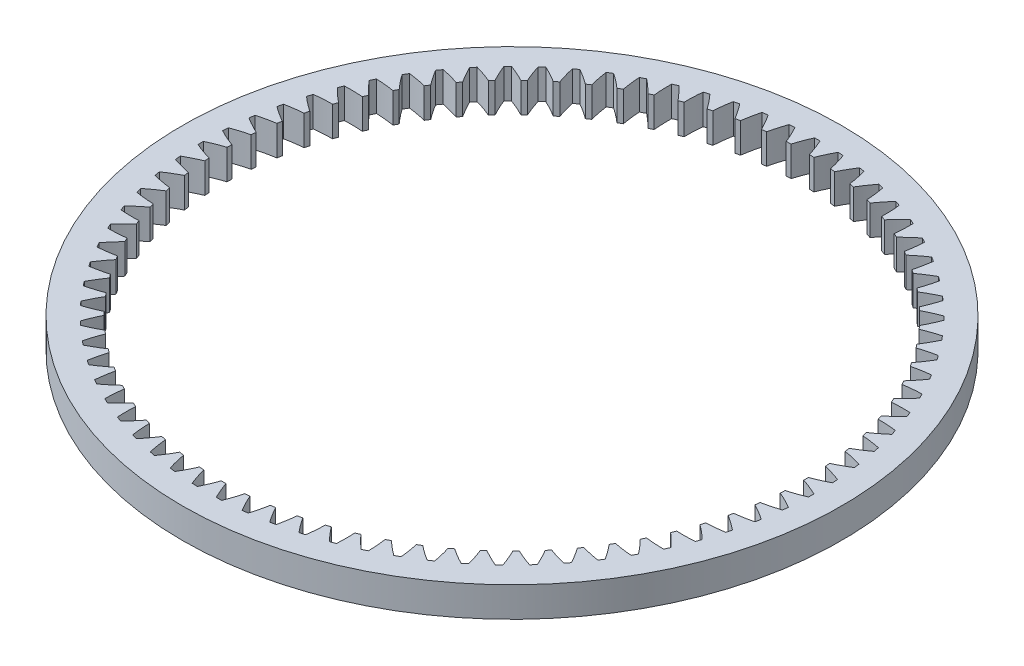
from build123d import *

# Parameters (mm, degrees)
SKETCH1_R           = 34.925
BOSS_EXTRUDE1_DEPTH = 3.175


with BuildPart() as part:
    # Sketch1 → Boss-Extrude1 (new body)
    with BuildSketch(Plane(origin=(0, 0, 0), x_dir=(1, 0, 0), z_dir=(0, 1, 0))):
        Circle(SKETCH1_R)
        with BuildLine():
            ThreePointArc((-21.018450197, 24.604762777), (-21.235465246, 24.417711108), (-21.450815724, 24.228745423))
            ThreePointArc((-21.450815724, 24.228745423), (-21.140636423, 23.310386195), (-20.774375306, 22.412918834))
            ThreePointArc((-20.774375306, 22.412918834), (-20.955169098, 22.243976445), (-21.134589057, 22.073575728))
            ThreePointArc((-21.134589057, 22.073575728), (-22.008625513, 22.492688056), (-22.906860003, 22.857063783))
            ThreePointArc((-22.906860003, 22.857063783), (-23.108327747, 22.653361533), (-23.307984112, 22.447883567))
            ThreePointArc((-23.307984112, 22.447883567), (-22.925821544, 21.557071218), (-22.489414305, 20.691540403))
            ThreePointArc((-22.489414305, 20.691540403), (-22.656214078, 20.508767971), (-22.821528496, 20.324650972))
            ThreePointArc((-22.821528496, 20.324650972), (-23.726100526, 20.672996076), (-24.650445265, 20.964855073))
            ThreePointArc((-24.650445265, 20.964855073), (-24.835091959, 20.745790112), (-25.017791919, 20.525098964))
            ThreePointArc((-25.017791919, 20.525098964), (-24.566062239, 19.667465496), (-24.062267985, 18.839343391))
            ThreePointArc((-24.062267985, 18.839343391), (-24.214019177, 18.643896462), (-24.364182883, 18.447227229))
            ThreePointArc((-24.364182883, 18.447227229), (-25.293571493, 18.722602759), (-26.238182475, 18.940099799))
            ThreePointArc((-26.238182475, 18.940099799), (-26.404840724, 18.707057127), (-26.569429191, 18.472548077))
            ThreePointArc((-26.569429191, 18.472548077), (-26.050988379, 17.653515724), (-25.482992261, 16.868037984))
            ThreePointArc((-25.482992261, 16.868037984), (-25.618735451, 16.661152237), (-25.752799063, 16.453174175))
            ThreePointArc((-25.752799063, 16.453174175), (-26.701128357, 16.653839119), (-27.660033448, 16.795599116))
            ThreePointArc((-27.660033448, 16.795599116), (-27.807649584, 16.550052104), (-27.953085978, 16.303207793))
            ThreePointArc((-27.953085978, 16.303207793), (-27.371211783, 15.527954743), (-26.742604854, 14.790087411))
            ThreePointArc((-26.742604854, 14.790087411), (-26.861481832, 14.573070844), (-26.978597754, 14.355098857))
            ThreePointArc((-26.978597754, 14.355098857), (-27.93987209, 14.479784546), (-28.907008784, 14.544911247))
            ThreePointArc((-28.907008784, 14.544911247), (-29.03464953, 14.288412322), (-29.160014354, 14.03079338))
            ThreePointArc((-29.160014354, 14.03079338), (-28.518385573, 13.304221032), (-27.833142089, 12.618629143))
            ThreePointArc((-27.833142089, 12.618629143), (-27.934401275, 12.392853804), (-28.033829065, 12.166265983))
            ThreePointArc((-28.033829065, 12.166265983), (-29.001970957, 12.214184114), (-29.971224702, 12.202265767))
            ThreePointArc((-29.971224702, 12.202265767), (-30.078083073, 11.936436598), (-30.182583731, 11.669671774))
            ThreePointArc((-30.182583731, 11.669671774), (-29.485256947, 10.996373752), (-28.747709239, 10.367391838))
            ThreePointArc((-28.747709239, 10.367391838), (-28.83071044, 10.134285153), (-28.911821482, 9.900514057))
            ThreePointArc((-28.911821482, 9.900514057), (-29.880710025, 9.871361676), (-30.845952889, 9.782473633))
            ThreePointArc((-30.845952889, 9.782473633), (-30.931353291, 9.508994878), (-31.014329096, 9.234770746))
            ThreePointArc((-31.014329096, 9.234770746), (-30.265713034, 8.619003856), (-29.480524114, 8.050608544))
            ThreePointArc((-29.480524114, 8.050608544), (-29.54474257, 7.811644287), (-29.607024055, 7.572167894))
            ThreePointArc((-29.607024055, 7.572167894), (-30.570533624, 7.466129312), (-31.525663029, 7.300833552))
            ThreePointArc((-31.525663029, 7.300833552), (-31.589065535, 7.02143423), (-31.649991887, 6.741484524))
            ThreePointArc((-31.649991887, 6.741484524), (-30.854819538, 6.187141843), (-30.026953625, 5.682926711))
            ThreePointArc((-30.026953625, 5.682926711), (-30.071983325, 5.439615692), (-30.115041489, 5.195948048))
            ThreePointArc((-30.115041489, 5.195948048), (-31.067080466, 5.013693675), (-32.006057778, 4.77303525))
            ThreePointArc((-32.006057778, 4.77303525), (-32.047061535, 4.489481815), (-32.085553238, 4.205576466))
            ThreePointArc((-32.085553238, 4.205576466), (-31.248851939, 3.716162728), (-30.383543067, 3.279315586))
            ThreePointArc((-30.383543067, 3.279315586), (-30.40909932, 3.033196095), (-30.432661935, 2.786877745))
            ThreePointArc((-30.432661935, 2.786877745), (-31.367211223, 2.529559852), (-32.284099925, 2.215060283))
            ThreePointArc((-32.284099925, 2.215060283), (-32.302445694, 1.92914545), (-32.318259391, 1.643079399))
            ThreePointArc((-32.318259391, 1.643079399), (-31.445319037, 1.221688835), (-30.548037967, 0.854971572))
            ThreePointArc((-30.548037967, 0.854971572), (-30.553959198, 0.607599655), (-30.557877293, 0.360187904))
            ThreePointArc((-30.557877293, 0.360187904), (-31.469028371, 0.029433337), (-32.358031597, -0.356919009))
            ThreePointArc((-32.358031597, -0.356919009), (-32.353603391, -0.643387593), (-32.346639103, -0.929805744))
            ThreePointArc((-32.346639103, -0.929805744), (-31.442978703, -1.280508968), (-30.519398335, -1.574777848))
            ThreePointArc((-30.519398335, -1.574777848), (-30.505647108, -1.821838225), (-30.489895913, -2.068779161))
            ThreePointArc((-30.489895913, -2.068779161), (-31.37188819, -2.470879265), (-32.227385375, -2.926641744))
            ThreePointArc((-32.227385375, -2.926641744), (-32.200211191, -3.211852933), (-32.170512948, -3.496812356))
            ThreePointArc((-32.170512948, -3.496812356), (-31.241845734, -3.774610981), (-30.297805241, -3.994571015))
            ThreePointArc((-30.297805241, -3.994571015), (-30.264468495, -4.239757858), (-30.229147594, -4.484666739))
            ThreePointArc((-30.229147594, -4.484666739), (-31.076404831, -4.955570173), (-31.892987246, -5.477861307))
            ThreePointArc((-31.892987246, -5.477861307), (-31.843238888, -5.760011904), (-31.790994452, -6.041710994))
            ThreePointArc((-31.790994452, -6.041710994), (-30.843191758, -6.244848688), (-29.884659667, -6.389109219))
            ThreePointArc((-29.884659667, -6.389109219), (-29.831948169, -6.630872376), (-29.777280871, -6.872200809))
            ThreePointArc((-29.777280871, -6.872200809), (-30.584446434, -7.408930371), (-31.356951384, -7.994448068))
            ThreePointArc((-31.356951384, -7.994448068), (-31.284943376, -8.271754226), (-31.210483054, -8.548411991))
            ThreePointArc((-31.210483054, -8.548411991), (-30.249537192, -8.675604451), (-29.282573652, -8.743253416))
            ThreePointArc((-29.282573652, -8.743253416), (-29.210820661, -8.980064384), (-29.13715259, -9.216286613))
            ThreePointArc((-29.13715259, -9.216286613), (-29.899123321, -9.815448925), (-30.622666779, -10.460491353))
            ThreePointArc((-30.622666779, -10.460491353), (-30.528854379, -10.731199854), (-30.432648932, -11.001067174))
            ThreePointArc((-30.432648932, -11.001067174), (-29.464635313, -11.05151025), (-28.495353779, -11.042119951))
            ThreePointArc((-28.495353779, -11.042119951), (-28.405012939, -11.272481533), (-28.31280985, -11.502104086))
            ThreePointArc((-28.31280985, -11.502104086), (-29.024768322, -12.159911051), (-29.694775815, -12.860400045))
            ThreePointArc((-29.694775815, -12.860400045), (-29.579752135, -13.122799382), (-29.462409806, -13.384170069))
            ThreePointArc((-29.462409806, -13.384170069), (-28.493448523, -13.357544842), (-27.527977105, -13.271174648))
            ThreePointArc((-27.527977105, -13.271174648), (-27.419619581, -13.493630425), (-27.30946441, -13.715201553))
            ThreePointArc((-27.30946441, -13.715201553), (-27.966909394, -14.427494304), (-28.579144917, -15.179001147))
            ThreePointArc((-28.579144917, -15.179001147), (-28.443637175, -15.431432346), (-28.305899839, -15.682653931))
            ThreePointArc((-28.305899839, -15.682653931), (-27.342116977, -15.579128735), (-26.386559696, -15.416324705))
            ThreePointArc((-26.386559696, -15.416324705), (-26.260870559, -15.629468241), (-26.133459743, -15.8415871))
            ThreePointArc((-26.133459743, -15.8415871), (-26.73223466, -16.603862293), (-27.282827463, -17.401635716))
            ThreePointArc((-27.282827463, -17.401635716), (-27.127692382, -17.642502827), (-26.970430859, -17.881987006))
            ThreePointArc((-26.970430859, -17.881987006), (-26.017919764, -17.70221636), (-25.078317961, -17.464007795))
            ThreePointArc((-25.078317961, -17.464007795), (-24.936091858, -17.666491527), (-24.79223093, -17.867817033))
            ThreePointArc((-24.79223093, -17.867817033), (-25.328550131, -18.675255319), (-25.814019191, -19.514251542))
            ThreePointArc((-25.814019191, -19.514251542), (-25.640237584, -19.742031725), (-25.464446132, -19.968264401))
            ThreePointArc((-25.464446132, -19.968264401), (-24.529228886, -19.713384874), (-23.611523025, -19.401277804))
            ThreePointArc((-23.611523025, -19.401277804), (-23.453659155, -19.591821565), (-23.29425765, -19.781080874))
            ThreePointArc((-23.29425765, -19.781080874), (-23.764730353, -20.628577367), (-24.182006377, -21.503491986))
            ThreePointArc((-24.182006377, -21.503491986), (-23.990676949, -21.716745142), (-23.797466977, -21.928296))
            ThreePointArc((-23.797466977, -21.928296), (-22.885456325, -21.599919022), (-21.995448439, -21.215886688))
            ThreePointArc((-21.995448439, -21.215886688), (-21.822944868, -21.393285799), (-21.649010573, -21.569282353))
            ThreePointArc((-21.649010573, -21.569282353), (-22.050662298, -22.451478908), (-22.397107133, -23.35678043))
            ThreePointArc((-22.397107133, -23.35678043), (-22.189439529, -23.554158304), (-21.980032575, -23.749689851))
            ThreePointArc((-21.980032575, -23.749689851), (-21.09699454, -23.349891527), (-20.240311545, -22.896361906))
            ThreePointArc((-20.240311545, -22.896361906), (-20.054258898, -23.059494792), (-19.866891481, -23.221115884))
            ThreePointArc((-19.866891481, -23.221115884), (-20.197182857, -24.13243497), (-20.470606167, -25.062399789))
            ThreePointArc((-20.470606167, -25.062399789), (-20.247913328, -25.242654493), (-20.023633329, -25.420930516))
            ThreePointArc((-20.023633329, -25.420930516), (-19.175150764, -24.952238499), (-18.357208886, -24.432078952))
            ThreePointArc((-18.357208886, -24.432078952), (-18.158783445, -24.579914235), (-17.959167504, -24.726138044))
            ThreePointArc((-17.959167504, -24.726138044), (-18.216010323, -25.660818009), (-18.414683437, -26.609566586))
            ThreePointArc((-18.414683437, -26.609566586), (-18.1783733, -26.771558493), (-17.940638226, -26.931451874))
            ThreePointArc((-17.940638226, -26.931451874), (-17.13207551, -26.396829387), (-16.358046041, -25.813328529))
            ThreePointArc((-16.358046041, -25.813328529), (-16.148502318, -25.944931546), (-15.937899889, -26.074833598))
            ThreePointArc((-15.937899889, -26.074833598), (-16.119670306, -27.026965093), (-16.24233715, -27.988499136))
            ThreePointArc((-16.24233715, -27.988499136), (-15.993903744, -28.131204081), (-15.744216633, -28.271703921))
            ThreePointArc((-15.744216633, -28.271703921), (-14.980685759, -27.674531019), (-14.255462362, -27.031377931))
            ThreePointArc((-14.255462362, -27.031377931), (-14.036125159, -27.145916646), (-13.815867738, -27.258675658))
            ThreePointArc((-13.815867738, -27.258675658), (-13.921416544, -28.222239003), (-13.967301578, -29.190479383))
            ThreePointArc((-13.967301578, -29.190479383), (-13.708315578, -29.312995139), (-13.448255032, -29.433213154))
            ThreePointArc((-13.448255032, -29.433213154), (-12.734583289, -28.777265356), (-12.062751061, -28.078526258))
            ThreePointArc((-12.062751061, -28.078526258), (-11.835007097, -28.17527652), (-11.606487224, -28.270179595))
            ThreePointArc((-11.606487224, -28.270179595), (-11.635147104, -29.239082831), (-11.603960228, -30.207908021))
            ThreePointArc((-11.603960228, -30.207908021), (-11.336059027, -30.309460004), (-11.067269233, -30.408636137))
            ThreePointArc((-11.067269233, -30.408636137), (-10.407968684, -29.698060556), (-9.793775163, -28.948153103))
            ThreePointArc((-9.793775163, -28.948153103), (-9.559064311, -29.026503226), (-9.32372676, -29.102950354))
            ThreePointArc((-9.32372676, -29.102950354), (-9.275316518, -30.071067764), (-9.167254905, -31.034352539))
            ThreePointArc((-9.167254905, -31.034352539), (-8.892132262, -31.114298704), (-8.616312595, -31.191805931))
            ThreePointArc((-8.616312595, -31.191805931), (-8.015551549, -30.431095056), (-7.462879866, -29.634760402))
            ThreePointArc((-7.462879866, -29.634760402), (-7.222686042, -29.694215032), (-6.982018694, -29.751722891))
            ThreePointArc((-6.982018694, -29.751722891), (-6.856844394, -30.712933723), (-6.672591246, -31.664587887))
            ThreePointArc((-6.672591246, -31.664587887), (-6.391986573, -31.72242279), (-6.110880855, -31.777771086))
            ThreePointArc((-6.110880855, -31.777771086), (-5.572457517, -30.971734374), (-5.084801839, -30.134007205))
            ThreePointArc((-5.084801839, -30.134007205), (-4.840643626, -30.17419045), (-4.596168057, -30.212395456))
            ThreePointArc((-4.596168057, -30.212395456), (-4.395021093, -31.160622628), (-4.135741316, -32.094629516))
            ThreePointArc((-4.135741316, -32.094629516), (-3.851428687, -32.129987505), (-3.566814158, -32.16282694))
            ThreePointArc((-3.566814158, -32.16282694), (-3.094132615, -31.316560416), (-2.674576058, -30.442737113))
            ThreePointArc((-2.674576058, -30.442737113), (-2.427997103, -30.46339492), (-2.181258967, -30.48205553))
            ThreePointArc((-2.181258967, -30.48205553), (-1.905411053, -31.411304043), (-1.572743898, -32.321758563))
            ThreePointArc((-1.572743898, -32.321758563), (-1.286520829, -32.334416094), (-1.000196913, -32.344539047))
            ThreePointArc((-1.000196913, -32.344539047), (-0.596245609, -31.46339308), (-0.247440746, -30.558998234))
            ThreePointArc((-0.247440746, -30.558998234), (0, -30.56), (0.247440746, -30.558998234))
            ThreePointArc((0.247440746, -30.558998234), (0.596245609, -31.46339308), (1.000196913, -32.344539047))
            ThreePointArc((1.000196913, -32.344539047), (1.286520829, -32.334416094), (1.572743898, -32.321758563))
            ThreePointArc((1.572743898, -32.321758563), (1.905411053, -31.411304043), (2.181258967, -30.48205553))
            ThreePointArc((2.181258967, -30.48205553), (2.427997103, -30.46339492), (2.674576058, -30.442737113))
            ThreePointArc((2.674576058, -30.442737113), (3.094132615, -31.316560416), (3.566814158, -32.16282694))
            ThreePointArc((3.566814158, -32.16282694), (3.851428687, -32.129987505), (4.135741316, -32.094629516))
            ThreePointArc((4.135741316, -32.094629516), (4.395021093, -31.160622628), (4.596168057, -30.212395456))
            ThreePointArc((4.596168057, -30.212395456), (4.840643626, -30.17419045), (5.084801839, -30.134007205))
            ThreePointArc((5.084801839, -30.134007205), (5.572457517, -30.971734374), (6.110880855, -31.777771086))
            ThreePointArc((6.110880855, -31.777771086), (6.391986573, -31.72242279), (6.672591246, -31.664587887))
            ThreePointArc((6.672591246, -31.664587887), (6.856844394, -30.712933723), (6.982018694, -29.751722891))
            ThreePointArc((6.982018694, -29.751722891), (7.222686042, -29.694215032), (7.462879866, -29.634760402))
            ThreePointArc((7.462879866, -29.634760402), (8.015551549, -30.431095056), (8.616312595, -31.191805931))
            ThreePointArc((8.616312595, -31.191805931), (8.892132262, -31.114298704), (9.167254905, -31.034352539))
            ThreePointArc((9.167254905, -31.034352539), (9.275316518, -30.071067764), (9.32372676, -29.102950354))
            ThreePointArc((9.32372676, -29.102950354), (9.559064311, -29.026503226), (9.793775163, -28.948153103))
            ThreePointArc((9.793775163, -28.948153103), (10.407968684, -29.698060556), (11.067269233, -30.408636137))
            ThreePointArc((11.067269233, -30.408636137), (11.336059027, -30.309460004), (11.603960228, -30.207908021))
            ThreePointArc((11.603960228, -30.207908021), (11.635147104, -29.239082831), (11.606487224, -28.270179595))
            ThreePointArc((11.606487224, -28.270179595), (11.835007097, -28.17527652), (12.062751061, -28.078526258))
            ThreePointArc((12.062751061, -28.078526258), (12.734583289, -28.777265356), (13.448255032, -29.433213154))
            ThreePointArc((13.448255032, -29.433213154), (13.708315578, -29.312995139), (13.967301578, -29.190479383))
            ThreePointArc((13.967301578, -29.190479383), (13.921416544, -28.222239003), (13.815867738, -27.258675658))
            ThreePointArc((13.815867738, -27.258675658), (14.036125159, -27.145916646), (14.255462362, -27.031377931))
            ThreePointArc((14.255462362, -27.031377931), (14.980685759, -27.674531019), (15.744216633, -28.271703921))
            ThreePointArc((15.744216633, -28.271703921), (15.993903744, -28.131204081), (16.24233715, -27.988499136))
            ThreePointArc((16.24233715, -27.988499136), (16.119670306, -27.026965093), (15.937899889, -26.074833598))
            ThreePointArc((15.937899889, -26.074833598), (16.148502318, -25.944931546), (16.358046041, -25.813328529))
            ThreePointArc((16.358046041, -25.813328529), (17.13207551, -26.396829387), (17.940638226, -26.931451874))
            ThreePointArc((17.940638226, -26.931451874), (18.1783733, -26.771558493), (18.414683437, -26.609566586))
            ThreePointArc((18.414683437, -26.609566586), (18.216010323, -25.660818009), (17.959167504, -24.726138044))
            ThreePointArc((17.959167504, -24.726138044), (18.158783445, -24.579914235), (18.357208886, -24.432078952))
            ThreePointArc((18.357208886, -24.432078952), (19.175150764, -24.952238499), (20.023633329, -25.420930516))
            ThreePointArc((20.023633329, -25.420930516), (20.247913328, -25.242654493), (20.470606167, -25.062399789))
            ThreePointArc((20.470606167, -25.062399789), (20.197182857, -24.13243497), (19.866891481, -23.221115884))
            ThreePointArc((19.866891481, -23.221115884), (20.054258898, -23.059494792), (20.240311545, -22.896361906))
            ThreePointArc((20.240311545, -22.896361906), (21.09699454, -23.349891527), (21.980032575, -23.749689851))
            ThreePointArc((21.980032575, -23.749689851), (22.189439529, -23.554158304), (22.397107133, -23.35678043))
            ThreePointArc((22.397107133, -23.35678043), (22.050662298, -22.451478908), (21.649010573, -21.569282353))
            ThreePointArc((21.649010573, -21.569282353), (21.822944868, -21.393285799), (21.995448439, -21.215886688))
            ThreePointArc((21.995448439, -21.215886688), (22.885456325, -21.599919022), (23.797466977, -21.928296))
            ThreePointArc((23.797466977, -21.928296), (23.990676949, -21.716745142), (24.182006377, -21.503491986))
            ThreePointArc((24.182006377, -21.503491986), (23.764730353, -20.628577367), (23.29425765, -19.781080874))
            ThreePointArc((23.29425765, -19.781080874), (23.453659155, -19.591821565), (23.611523025, -19.401277804))
            ThreePointArc((23.611523025, -19.401277804), (24.529228886, -19.713384874), (25.464446132, -19.968264401))
            ThreePointArc((25.464446132, -19.968264401), (25.640237584, -19.742031725), (25.814019191, -19.514251542))
            ThreePointArc((25.814019191, -19.514251542), (25.328550131, -18.675255319), (24.79223093, -17.867817033))
            ThreePointArc((24.79223093, -17.867817033), (24.936091858, -17.666491527), (25.078317961, -17.464007795))
            ThreePointArc((25.078317961, -17.464007795), (26.017919764, -17.70221636), (26.970430859, -17.881987006))
            ThreePointArc((26.970430859, -17.881987006), (27.127692382, -17.642502827), (27.282827463, -17.401635716))
            ThreePointArc((27.282827463, -17.401635716), (26.73223466, -16.603862293), (26.133459743, -15.8415871))
            ThreePointArc((26.133459743, -15.8415871), (26.260870559, -15.629468241), (26.386559696, -15.416324705))
            ThreePointArc((26.386559696, -15.416324705), (27.342116977, -15.579128735), (28.305899839, -15.682653931))
            ThreePointArc((28.305899839, -15.682653931), (28.443637175, -15.431432346), (28.579144917, -15.179001147))
            ThreePointArc((28.579144917, -15.179001147), (27.966909394, -14.427494304), (27.30946441, -13.715201553))
            ThreePointArc((27.30946441, -13.715201553), (27.419619581, -13.493630425), (27.527977105, -13.271174648))
            ThreePointArc((27.527977105, -13.271174648), (28.493448523, -13.357544842), (29.462409806, -13.384170069))
            ThreePointArc((29.462409806, -13.384170069), (29.579752135, -13.122799382), (29.694775815, -12.860400045))
            ThreePointArc((29.694775815, -12.860400045), (29.024768322, -12.159911051), (28.31280985, -11.502104086))
            ThreePointArc((28.31280985, -11.502104086), (28.405012939, -11.272481533), (28.495353779, -11.042119951))
            ThreePointArc((28.495353779, -11.042119951), (29.464635313, -11.05151025), (30.432648932, -11.001067174))
            ThreePointArc((30.432648932, -11.001067174), (30.528854379, -10.731199854), (30.622666779, -10.460491353))
            ThreePointArc((30.622666779, -10.460491353), (29.899123321, -9.815448925), (29.13715259, -9.216286613))
            ThreePointArc((29.13715259, -9.216286613), (29.210820661, -8.980064384), (29.282573652, -8.743253416))
            ThreePointArc((29.282573652, -8.743253416), (30.249537192, -8.675604451), (31.210483054, -8.548411991))
            ThreePointArc((31.210483054, -8.548411991), (31.284943376, -8.271754226), (31.356951384, -7.994448068))
            ThreePointArc((31.356951384, -7.994448068), (30.584446434, -7.408930371), (29.777280871, -6.872200809))
            ThreePointArc((29.777280871, -6.872200809), (29.831948169, -6.630872376), (29.884659667, -6.389109219))
            ThreePointArc((29.884659667, -6.389109219), (30.843191758, -6.244848688), (31.790994452, -6.041710994))
            ThreePointArc((31.790994452, -6.041710994), (31.843238888, -5.760011904), (31.892987246, -5.477861307))
            ThreePointArc((31.892987246, -5.477861307), (31.076404831, -4.955570173), (30.229147594, -4.484666739))
            ThreePointArc((30.229147594, -4.484666739), (30.264468495, -4.239757858), (30.297805241, -3.994571015))
            ThreePointArc((30.297805241, -3.994571015), (31.241845734, -3.774610981), (32.170512948, -3.496812356))
            ThreePointArc((32.170512948, -3.496812356), (32.200211191, -3.211852933), (32.227385375, -2.926641744))
            ThreePointArc((32.227385375, -2.926641744), (31.37188819, -2.470879265), (30.489895913, -2.068779161))
            ThreePointArc((30.489895913, -2.068779161), (30.505647108, -1.821838225), (30.519398335, -1.574777848))
            ThreePointArc((30.519398335, -1.574777848), (31.442978703, -1.280508968), (32.346639103, -0.929805744))
            ThreePointArc((32.346639103, -0.929805744), (32.353603391, -0.643387593), (32.358031597, -0.356919009))
            ThreePointArc((32.358031597, -0.356919009), (31.469028371, 0.029433337), (30.557877293, 0.360187904))
            ThreePointArc((30.557877293, 0.360187904), (30.553959198, 0.607599655), (30.548037967, 0.854971572))
            ThreePointArc((30.548037967, 0.854971572), (31.445319037, 1.221688835), (32.318259391, 1.643079399))
            ThreePointArc((32.318259391, 1.643079399), (32.302445694, 1.92914545), (32.284099925, 2.215060283))
            ThreePointArc((32.284099925, 2.215060283), (31.367211223, 2.529559852), (30.432661935, 2.786877745))
            ThreePointArc((30.432661935, 2.786877745), (30.40909932, 3.033196095), (30.383543067, 3.279315586))
            ThreePointArc((30.383543067, 3.279315586), (31.248851939, 3.716162728), (32.085553238, 4.205576466))
            ThreePointArc((32.085553238, 4.205576466), (32.047061535, 4.489481815), (32.006057778, 4.77303525))
            ThreePointArc((32.006057778, 4.77303525), (31.067080466, 5.013693675), (30.115041489, 5.195948048))
            ThreePointArc((30.115041489, 5.195948048), (30.071983325, 5.439615692), (30.026953625, 5.682926711))
            ThreePointArc((30.026953625, 5.682926711), (30.854819538, 6.187141843), (31.649991887, 6.741484524))
            ThreePointArc((31.649991887, 6.741484524), (31.589065535, 7.02143423), (31.525663029, 7.300833552))
            ThreePointArc((31.525663029, 7.300833552), (30.570533624, 7.466129312), (29.607024055, 7.572167894))
            ThreePointArc((29.607024055, 7.572167894), (29.54474257, 7.811644287), (29.480524114, 8.050608544))
            ThreePointArc((29.480524114, 8.050608544), (30.265713034, 8.619003856), (31.014329096, 9.234770746))
            ThreePointArc((31.014329096, 9.234770746), (30.931353291, 9.508994878), (30.845952889, 9.782473633))
            ThreePointArc((30.845952889, 9.782473633), (29.880710025, 9.871361676), (28.911821482, 9.900514057))
            ThreePointArc((28.911821482, 9.900514057), (28.83071044, 10.134285153), (28.747709239, 10.367391838))
            ThreePointArc((28.747709239, 10.367391838), (29.485256947, 10.996373752), (30.182583731, 11.669671774))
            ThreePointArc((30.182583731, 11.669671774), (30.078083073, 11.936436598), (29.971224702, 12.202265767))
            ThreePointArc((29.971224702, 12.202265767), (29.001970957, 12.214184114), (28.033829065, 12.166265983))
            ThreePointArc((28.033829065, 12.166265983), (27.934401275, 12.392853804), (27.833142089, 12.618629143))
            ThreePointArc((27.833142089, 12.618629143), (28.518385573, 13.304221032), (29.160014354, 14.03079338))
            ThreePointArc((29.160014354, 14.03079338), (29.03464953, 14.288412322), (28.907008784, 14.544911247))
            ThreePointArc((28.907008784, 14.544911247), (27.93987209, 14.479784546), (26.978597754, 14.355098857))
            ThreePointArc((26.978597754, 14.355098857), (26.861481832, 14.573070844), (26.742604854, 14.790087411))
            ThreePointArc((26.742604854, 14.790087411), (27.371211783, 15.527954743), (27.953085978, 16.303207793))
            ThreePointArc((27.953085978, 16.303207793), (27.807649584, 16.550052104), (27.660033448, 16.795599116))
            ThreePointArc((27.660033448, 16.795599116), (26.701128357, 16.653839119), (25.752799063, 16.453174175))
            ThreePointArc((25.752799063, 16.453174175), (25.618735451, 16.661152237), (25.482992261, 16.868037984))
            ThreePointArc((25.482992261, 16.868037984), (26.050988379, 17.653515724), (26.569429191, 18.472548077))
            ThreePointArc((26.569429191, 18.472548077), (26.404840724, 18.707057127), (26.238182475, 18.940099799))
            ThreePointArc((26.238182475, 18.940099799), (25.293571493, 18.722602759), (24.364182883, 18.447227229))
            ThreePointArc((24.364182883, 18.447227229), (24.214019177, 18.643896462), (24.062267985, 18.839343391))
            ThreePointArc((24.062267985, 18.839343391), (24.566062239, 19.667465496), (25.017791919, 20.525098964))
            ThreePointArc((25.017791919, 20.525098964), (24.835091959, 20.745790112), (24.650445265, 20.964855073))
            ThreePointArc((24.650445265, 20.964855073), (23.726100526, 20.672996076), (22.821528496, 20.324650972))
            ThreePointArc((22.821528496, 20.324650972), (22.656214078, 20.508767971), (22.489414305, 20.691540403))
            ThreePointArc((22.489414305, 20.691540403), (22.925821544, 21.557071218), (23.307984112, 22.447883567))
            ThreePointArc((23.307984112, 22.447883567), (23.108327747, 22.653361533), (22.906860003, 22.857063783))
            ThreePointArc((22.906860003, 22.857063783), (22.008625513, 22.492688056), (21.134589057, 22.073575728))
            ThreePointArc((21.134589057, 22.073575728), (20.955169098, 22.243976445), (20.774375306, 22.412918834))
            ThreePointArc((20.774375306, 22.412918834), (21.140636423, 23.310386195), (21.450815724, 24.228745423))
            ThreePointArc((21.450815724, 24.228745423), (21.235465246, 24.417711108), (21.018450197, 24.604762777))
            ThreePointArc((21.018450197, 24.604762777), (20.152004883, 24.17017402), (19.314029941, 23.682944231))
            ThreePointArc((19.314029941, 23.682944231), (19.121638792, 23.838551338), (18.927994017, 23.992595576))
            ThreePointArc((18.927994017, 23.992595576), (19.221793393, 24.916325405), (19.458028373, 25.856425349))
            ThreePointArc((19.458028373, 25.856425349), (19.228345298, 26.027684052), (18.997154981, 26.196902539))
            ThreePointArc((18.997154981, 26.196902539), (18.16797679, 25.694848361), (17.37136131, 25.142581535))
            ThreePointArc((17.37136131, 25.142581535), (17.167215329, 25.282411235), (16.961943856, 25.420583404))
            ThreePointArc((16.961943856, 25.420583404), (17.181423996, 26.364735584), (17.342221102, 27.320632629))
            ThreePointArc((17.342221102, 27.320632629), (17.099657559, 27.473101597), (16.855753635, 27.623417048))
            ThreePointArc((16.855753635, 27.623417048), (16.069084898, 27.057071599), (15.318865339, 26.443259344))
            ThreePointArc((15.318865339, 26.443259344), (15.104255204, 26.566427587), (14.888654825, 26.687854119))
            ThreePointArc((14.888654825, 26.687854119), (15.032428104, 27.646459416), (15.116770725, 28.612110073))
            ThreePointArc((15.116770725, 28.612110073), (14.862860279, 28.744825349), (14.607784788, 28.87528742))
            ThreePointArc((14.607784788, 28.87528742), (13.868599077, 28.248231318), (13.16951857, 27.576754353))
            ThreePointArc((13.16951857, 27.576754353), (12.945801114, 27.68248243), (12.721234925, 27.786395628))
            ThreePointArc((12.721234925, 27.786395628), (12.788392362, 28.75339343), (12.795747256, 29.722692546))
            ThreePointArc((12.795747256, 29.722692546), (12.532095212, 29.834815059), (12.267460821, 29.944598929))
            ThreePointArc((12.267460821, 29.944598929), (11.580431508, 29.260796623), (10.936909863, 28.535900242))
            ThreePointArc((10.936909863, 28.535900242), (10.705499502, 28.623519707), (10.473387281, 28.709262597))
            ThreePointArc((10.473387281, 28.709262597), (10.463504286, 29.678539233), (10.393824954, 30.645358586))
            ThreePointArc((10.393824954, 30.645358586), (10.122098203, 30.736179463), (9.849578018, 30.824591041))
            ThreePointArc((9.849578018, 30.824591041), (9.219048722, 30.088365752), (8.635154492, 29.314632983))
            ThreePointArc((8.635154492, 29.314632983), (8.397514274, 29.383589876), (8.159323511, 29.450620364))
            ThreePointArc((8.159323511, 29.450620364), (8.072462567, 30.416047755), (7.926189543, 31.374274802))
            ThreePointArc((7.926189543, 31.374274802), (7.648106031, 31.443219844), (7.369423011, 31.509700165))
            ThreePointArc((7.369423011, 31.509700165), (6.799380142, 30.725706544), (6.278804893, 29.908029175))
            ThreePointArc((6.278804893, 29.908029175), (6.036437258, 29.95788753), (5.79367387, 30.005781828))
            ThreePointArc((5.79367387, 30.005781828), (5.630384141, 30.96125623), (5.40844221, 31.904832751))
            ThreePointArc((5.40844221, 31.904832751), (5.12576007, 31.951466065), (4.842676139, 31.995594819))
            ThreePointArc((4.842676139, 31.995594819), (4.336723692, 31.168789527), (3.882758668, 30.312337177))
            ThreePointArc((3.882758668, 30.312337177), (3.637195941, 30.342781772), (3.391394758, 30.371237077))
            ThreePointArc((3.391394758, 30.371237077), (3.152708613, 31.310717675), (2.856500965, 32.233678075))
            ThreePointArc((2.856500965, 32.233678075), (2.571007403, 32.257704831), (2.28531231, 32.279203021))
            ThreePointArc((2.28531231, 32.279203021), (1.846649078, 31.414813387), (1.462164393, 30.525000824))
            ThreePointArc((1.462164393, 30.525000824), (1.214959101, 30.535839179), (0.967674156, 30.544675587))
            ThreePointArc((0.967674156, 30.544675587), (0.655100646, 31.462222682), (0.2865, 32.358731708))
            ThreePointArc((0.2865, 32.358731708), (0, 32.36), (-0.2865, 32.358731708))
            ThreePointArc((-0.2865, 32.358731708), (-0.655100646, 31.462222682), (-0.967674156, 30.544675587))
            ThreePointArc((-0.967674156, 30.544675587), (-1.214959101, 30.535839179), (-1.462164393, 30.525000824))
            ThreePointArc((-1.462164393, 30.525000824), (-1.846649078, 31.414813387), (-2.28531231, 32.279203021))
            ThreePointArc((-2.28531231, 32.279203021), (-2.571007403, 32.257704831), (-2.856500965, 32.233678075))
            ThreePointArc((-2.856500965, 32.233678075), (-3.152708613, 31.310717675), (-3.391394758, 30.371237077))
            ThreePointArc((-3.391394758, 30.371237077), (-3.637195941, 30.342781772), (-3.882758668, 30.312337177))
            ThreePointArc((-3.882758668, 30.312337177), (-4.336723692, 31.168789527), (-4.842676139, 31.995594819))
            ThreePointArc((-4.842676139, 31.995594819), (-5.12576007, 31.951466065), (-5.40844221, 31.904832751))
            ThreePointArc((-5.40844221, 31.904832751), (-5.630384141, 30.96125623), (-5.79367387, 30.005781828))
            ThreePointArc((-5.79367387, 30.005781828), (-6.036437258, 29.95788753), (-6.278804893, 29.908029175))
            ThreePointArc((-6.278804893, 29.908029175), (-6.799380142, 30.725706544), (-7.369423011, 31.509700165))
            ThreePointArc((-7.369423011, 31.509700165), (-7.648106031, 31.443219844), (-7.926189543, 31.374274802))
            ThreePointArc((-7.926189543, 31.374274802), (-8.072462567, 30.416047755), (-8.159323511, 29.450620364))
            ThreePointArc((-8.159323511, 29.450620364), (-8.397514274, 29.383589876), (-8.635154492, 29.314632983))
            ThreePointArc((-8.635154492, 29.314632983), (-9.219048722, 30.088365752), (-9.849578018, 30.824591041))
            ThreePointArc((-9.849578018, 30.824591041), (-10.122098203, 30.736179463), (-10.393824954, 30.645358586))
            ThreePointArc((-10.393824954, 30.645358586), (-10.463504286, 29.678539233), (-10.473387281, 28.709262597))
            ThreePointArc((-10.473387281, 28.709262597), (-10.705499502, 28.623519707), (-10.936909863, 28.535900242))
            ThreePointArc((-10.936909863, 28.535900242), (-11.580431508, 29.260796623), (-12.267460821, 29.944598929))
            ThreePointArc((-12.267460821, 29.944598929), (-12.532095212, 29.834815059), (-12.795747256, 29.722692546))
            ThreePointArc((-12.795747256, 29.722692546), (-12.788392362, 28.75339343), (-12.721234925, 27.786395628))
            ThreePointArc((-12.721234925, 27.786395628), (-12.945801114, 27.68248243), (-13.16951857, 27.576754353))
            ThreePointArc((-13.16951857, 27.576754353), (-13.868599077, 28.248231318), (-14.607784788, 28.87528742))
            ThreePointArc((-14.607784788, 28.87528742), (-14.862860279, 28.744825349), (-15.116770725, 28.612110073))
            ThreePointArc((-15.116770725, 28.612110073), (-15.032428104, 27.646459416), (-14.888654825, 26.687854119))
            ThreePointArc((-14.888654825, 26.687854119), (-15.104255204, 26.566427587), (-15.318865339, 26.443259344))
            ThreePointArc((-15.318865339, 26.443259344), (-16.069084898, 27.057071599), (-16.855753635, 27.623417048))
            ThreePointArc((-16.855753635, 27.623417048), (-17.099657559, 27.473101597), (-17.342221102, 27.320632629))
            ThreePointArc((-17.342221102, 27.320632629), (-17.181423996, 26.364735584), (-16.961943856, 25.420583404))
            ThreePointArc((-16.961943856, 25.420583404), (-17.167215329, 25.282411235), (-17.37136131, 25.142581535))
            ThreePointArc((-17.37136131, 25.142581535), (-18.16797679, 25.694848361), (-18.997154981, 26.196902539))
            ThreePointArc((-18.997154981, 26.196902539), (-19.228345298, 26.027684052), (-19.458028373, 25.856425349))
            ThreePointArc((-19.458028373, 25.856425349), (-19.221793393, 24.916325405), (-18.927994017, 23.992595576))
            ThreePointArc((-18.927994017, 23.992595576), (-19.121638792, 23.838551338), (-19.314029941, 23.682944231))
            ThreePointArc((-19.314029941, 23.682944231), (-20.152004883, 24.17017402), (-21.018450197, 24.604762777))
        make_face(mode=Mode.SUBTRACT)
    extrude(amount=BOSS_EXTRUDE1_DEPTH)


solid = part.part
